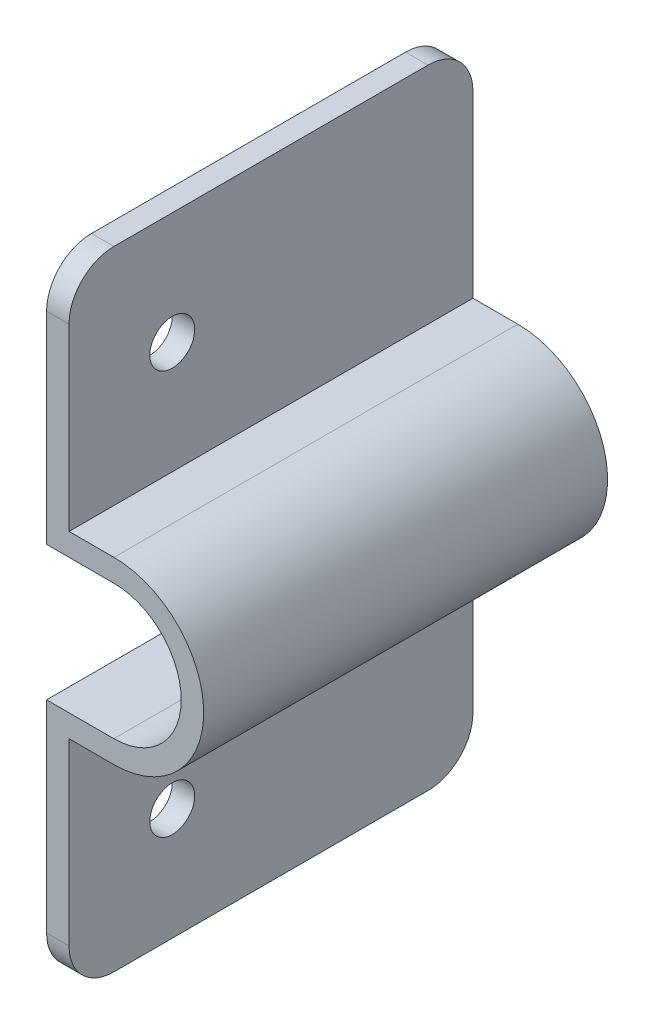
from build123d import *

# Parameters (mm, degrees)
BOSS_EXTRUDE1_DEPTH     = 88.9
SKETCH2_R               = 3.175
CUT_EXTRUDE1_DEPTH      = 4.175
FILLET1_R               = 6.35
SKETCH3_W               = 31.75
SKETCH3_H               = 57.15
CUT_EXTRUDE2_DEPTH      = 20.05
CUT_EXTRUDE2_DEPTH_BACK = 4.175
FILLET2_R               = 6.35


with BuildPart() as part:
    # Sketch1 → Boss-Extrude1 (new body)
    with BuildSketch(Plane.XY):
        with BuildLine():
            Line((13.335, 323.089397322), (10.16, 323.089397322))
            Line((10.16, 323.089397322), (10.16, 288.164397322))
            Line((10.16, 288.164397322), (19.685, 288.164397322))
            ThreePointArc((19.685, 288.164397322), (29.21, 278.639397322), (19.685, 269.114397322))
            Line((19.685, 269.114397322), (10.16, 269.114397322))
            Line((10.16, 269.114397322), (10.16, 234.189397322))
            Line((10.16, 234.189397322), (13.335, 234.189397322))
            Line((13.335, 234.189397322), (13.335, 265.939397322))
            Line((13.335, 265.939397322), (19.685, 265.939397322))
            ThreePointArc((19.685, 265.939397322), (32.385, 278.639397322), (19.685, 291.339397322))
            Line((19.685, 291.339397322), (13.335, 291.339397322))
            Line((13.335, 291.339397322), (13.335, 323.089397322))
        make_face()
    extrude(amount=-BOSS_EXTRUDE1_DEPTH)

    # Sketch2 → Cut-Extrude1 (cut, through all)
    with BuildSketch(Plane(origin=(13.335, 0, 0), x_dir=(0, 0, -1), z_dir=(1, 0, 0))):
        with Locations((46.355, 250.064397322)):
            Circle(SKETCH2_R)
        with Locations((46.355, 307.214397322)):
            Circle(SKETCH2_R)
    extrude(amount=-CUT_EXTRUDE1_DEPTH, mode=Mode.SUBTRACT)

    # Fillet1
    fillet1_edges = [part.edges().sort_by_distance(p)[0] for p in [
        (11.7475, 323.089397322, 0),
        (11.7475, 234.189397322, 0),
        (11.7475, 234.189397322, -88.9),
        (11.7475, 323.089397322, -88.9),
    ]]
    fillet(fillet1_edges, radius=FILLET1_R)

    # Sketch3 → Cut-Extrude2 (cut, two sides)
    with BuildSketch(Plane(origin=(13.335, 0, 0), x_dir=(0, 0, -1), z_dir=(1, 0, 0))) as cut_extrude2_sk:
        with Locations((15.875, 294.514397322)):
            Rectangle(SKETCH3_W, SKETCH3_H)
        with BuildLine():
            Line((31.75, 234.189397322), (31.75, 265.939397322))
            Line((31.75, 265.939397322), (0, 265.939397322))
            Line((0, 265.939397322), (0, 240.539397322))
            ThreePointArc((0, 240.539397322), (1.859871939, 236.049269261), (6.35, 234.189397322))
            Line((6.35, 234.189397322), (31.75, 234.189397322))
        make_face()
    extrude(amount=CUT_EXTRUDE2_DEPTH, mode=Mode.SUBTRACT)
    extrude(cut_extrude2_sk.sketch, amount=-CUT_EXTRUDE2_DEPTH_BACK, mode=Mode.SUBTRACT)

    # Fillet2
    fillet2_edges = [part.edges().sort_by_distance(p)[0] for p in [
        (11.7475, 234.189397322, -31.75),
        (11.7475, 323.089397322, -31.75),
    ]]
    fillet(fillet2_edges, radius=FILLET2_R)


solid = part.part
